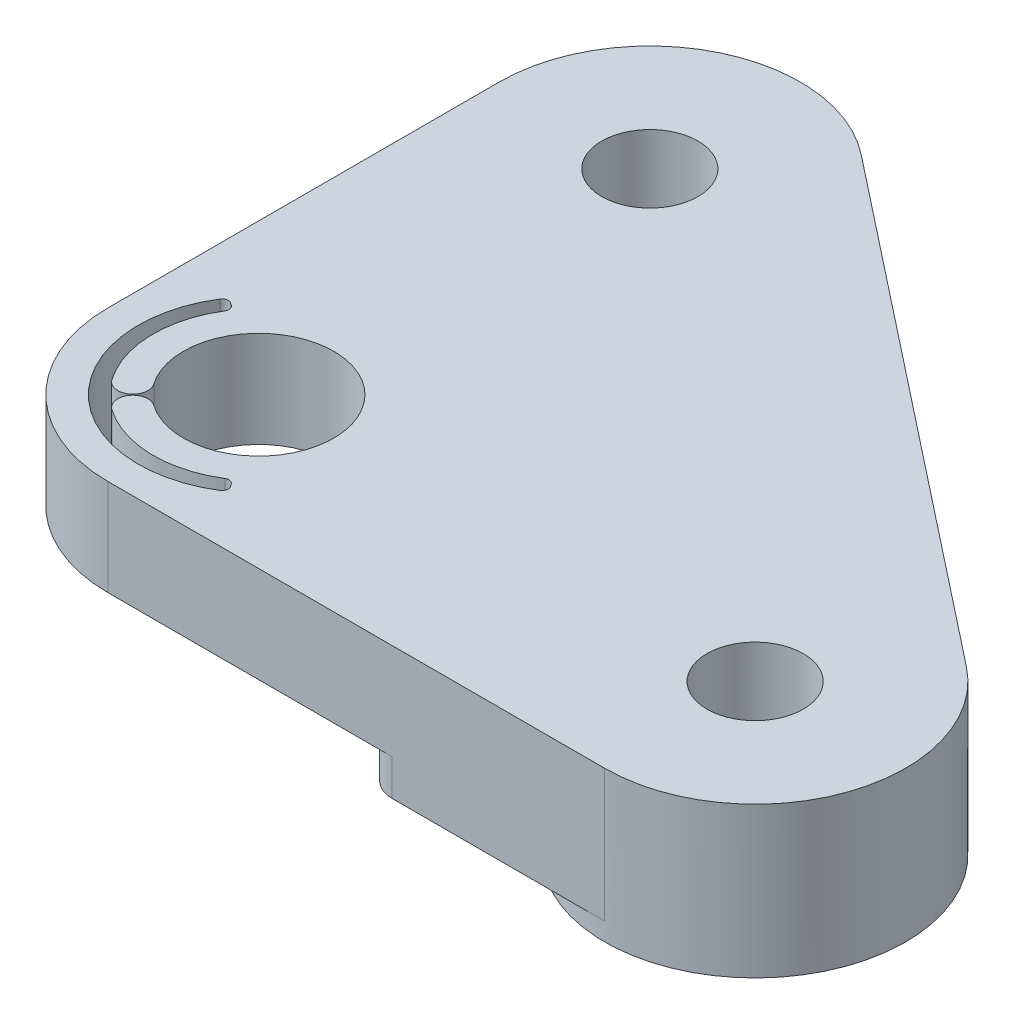
from build123d import *
from build123d.topology import SkipClean

# Parameters (mm, degrees)
SKETCH1_R               = 1.6
SKETCH1_R_2             = 2.5
BOSS_EXTRUDE1_DEPTH     = 1.57
FILLET1_R               = 5
SKETCH2_R               = 2.5
SKETCH2_R_2             = 1.6
BOSS_EXTRUDE2_DEPTH     = 2.83
SKETCH3_R               = 5
SKETCH3_R_2             = 1.6
BOSS_EXTRUDE3_DEPTH     = 0.6
CUT_EXTRUDE1_START      = -10
CUT_EXTRUDE1_DEPTH      = 10
SKETCH5_W               = 1.221153846
SKETCH5_H               = 0.325641026
PART_NUM_LEFT_DEPTH     = 0.4
CUT_EXTRUDE3_DEPTH      = 1
CUT_EXTRUDE3_DEPTH_BACK = 1.2
SKETCH8_R               = 9.25
FILLET3_R               = 1


with BuildPart() as part:
    # Sketch1 → Boss-Extrude1 (new body)
    with BuildSketch(Plane(origin=(0, 0, 0), x_dir=(1, 0, 0), z_dir=(0, 1, 0))):
        Polygon((-5, -5), (30.925365976, -5), (-5, 23.304833799), align=None)
        with Locations((16.5, 0)):
            Circle(SKETCH1_R, mode=Mode.SUBTRACT)
        Circle(SKETCH1_R_2, mode=Mode.SUBTRACT)
        with Locations((0, 13)):
            Circle(SKETCH1_R, mode=Mode.SUBTRACT)
    extrude(amount=BOSS_EXTRUDE1_DEPTH)

    # Fillet1
    fillet1_edges = [part.edges().sort_by_distance(p)[0] for p in [
        (-5, 0.785, -23.304833799),
        (-5, 0.785, 5),
        (30.925365976, 0.785, 5),
    ]]
    fillet(fillet1_edges, radius=FILLET1_R)

    # Sketch2 → Boss-Extrude2 (add)
    with BuildSketch(Plane(origin=(0, 1.57, 0), x_dir=(1, 0, 0), z_dir=(0, 1, 0))):
        with BuildLine():
            Line((19.594361133, 3.927458361), (3.094361133, 16.927458361))
            ThreePointArc((3.094361133, 16.927458361), (-2.182681188, 17.498433375), (-5, 13))
            Line((-5, 13), (-5, 0))
            ThreePointArc((-5, 0), (-3.535533906, -3.535533906), (0, -5))
            Line((0, -5), (16.5, -5))
            ThreePointArc((16.5, -5), (21.224261413, -1.637484075), (19.594361133, 3.927458361))
        make_face()
        Circle(SKETCH2_R, mode=Mode.SUBTRACT)
        with Locations((16.5, 0)):
            Circle(SKETCH2_R_2, mode=Mode.SUBTRACT)
        with Locations((0, 13)):
            Circle(SKETCH2_R_2, mode=Mode.SUBTRACT)
    extrude(amount=BOSS_EXTRUDE2_DEPTH)

    # Sketch3 → Boss-Extrude3 (add)
    # profile 1 of 2: a face of its own
    with SkipClean():  # the faces are left unmerged after this step: merging them gives an invalid solid
        with BuildSketch(Plane.XZ):
            with Locations((16.5, 0)):
                Circle(SKETCH3_R)
            with Locations((16.5, 0)):
                Circle(SKETCH3_R_2, mode=Mode.SUBTRACT)
        # profile 2 of 2: a face of its own
        with BuildSketch(Plane.XZ):
            with Locations((0, -13)):
                Circle(SKETCH3_R)
            with Locations((0, -13)):
                Circle(SKETCH3_R_2, mode=Mode.SUBTRACT)
        extrude(amount=BOSS_EXTRUDE3_DEPTH)
    add(part.part.scale(1), mode=Mode.REPLACE)  # the faces are merged on a copy

    # Sketch4 → Cut-Extrude1 (cut)
    with BuildSketch(Plane(origin=(0, 4.4, 0), x_dir=(1, 0, 0), z_dir=(0, 1, 0)).offset(CUT_EXTRUDE1_START)):
        with BuildLine():
            Line((2.119130133, -3.026431476), (2.176569541, -3.108463452))
            ThreePointArc((2.176569541, -3.108463452), (2.208718169, -3.263081334), (2.118672771, -3.392819725))
            ThreePointArc((2.118672771, -3.392819725), (-2.828427125, -2.828427125), (-3.392819725, 2.118672771))
            ThreePointArc((-3.392819725, 2.118672771), (-3.263081334, 2.208718169), (-3.108463452, 2.176569541))
            Line((-3.108463452, 2.176569541), (-3.026431476, 2.119130133))
            ThreePointArc((-3.026431476, 2.119130133), (-2.945196197, 1.995341896), (-2.971355046, 1.849607847))
            ThreePointArc((-2.971355046, 1.849607847), (-3.498720526, -0.094629188), (-2.867032155, -2.007517527))
            ThreePointArc((-2.867032155, -2.007517527), (-2.170667915, -2.130305331), (-2.047880111, -1.433941091))
            ThreePointArc((-2.047880111, -1.433941091), (-1.767766953, -1.767766953), (-1.433941091, -2.047880111))
            ThreePointArc((-1.433941091, -2.047880111), (-2.130305331, -2.170667915), (-2.007517527, -2.867032155))
            ThreePointArc((-2.007517527, -2.867032155), (-0.094629188, -3.498720526), (1.849607847, -2.971355046))
            ThreePointArc((1.849607847, -2.971355046), (1.995341896, -2.945196197), (2.119130133, -3.026431476))
        make_face()
    extrude(amount=CUT_EXTRUDE1_DEPTH, mode=Mode.SUBTRACT)

    # Sketch5 → Part Num Left (cut)
    # profile 1 of 6: a face of its own
    with BuildSketch(Plane(origin=(9.413907875, 0, -11.948421534), x_dir=(-0.7854916722275357, 0, -0.6188722266035127), z_dir=(0.6188722266035127, 0, -0.7854916722275357))):
        Polygon((-9.377508618, 3.775), (-9.09257272, 3.775), (-9.09257272, 0.925641026), (-7.871418874, 0.925641026), (-7.871418874, 0.6), (-9.377508618, 0.6), align=None)
    # profile 2 of 6: a face of its own
    with BuildSketch(Plane(origin=(9.413907875, 0, -11.948421534), x_dir=(-0.7854916722275357, 0, -0.6188722266035127), z_dir=(0.6188722266035127, 0, -0.7854916722275357))):
        with BuildLine():
            Line((-4.411482977, 3.192407853), (-4.660801887, 3.001602564))
            add(Edge.make_bspline(
                [(-4.660801887, 3.001602564), (-4.678587229, 3.022798837), (-4.713918127, 3.06490561), (-4.770758975, 3.124032768), (-4.829996894, 3.179427684), (-4.891609239, 3.231354246), (-4.956705012, 3.277996598), (-5.023707308, 3.321785384), (-5.093736963, 3.361035404), (-5.190576037, 3.408626827), (-5.317256585, 3.45828941), (-5.476727618, 3.499930199), (-5.6431984, 3.52643798), (-5.756770508, 3.529308943), (-5.814537865, 3.530769231)],
                knots=[0, 0, 0, 0, 0.757959112, 1.505699292, 2.245454638, 2.979532153, 3.711538275, 4.438200793, 5.171680507, 5.909471876, 7.393775596, 8.890124382, 10.418191784, 12, 12, 12, 12], degree=3))
            add(Edge.make_bspline(
                [(-5.814537865, 3.530769231), (-5.846363429, 3.530402779), (-5.909719187, 3.529673277), (-6.003743159, 3.520049285), (-6.096011427, 3.506522687), (-6.186463971, 3.486451858), (-6.274985655, 3.461076696), (-6.362155191, 3.430755071), (-6.446710521, 3.393240323), (-6.529821351, 3.351776402), (-6.609449636, 3.304942934), (-6.684792429, 3.253858679), (-6.755574943, 3.199095284), (-6.821853169, 3.140447495), (-6.883694865, 3.078179431), (-6.940651926, 3.011627492), (-6.992527262, 2.941004449), (-7.040349135, 2.867241573), (-7.083177829, 2.790553719), (-7.119037077, 2.710657048), (-7.150791723, 2.628919754), (-7.175918893, 2.544418344), (-7.195807562, 2.457747406), (-7.209530514, 2.368674334), (-7.219045056, 2.277385211), (-7.21977093, 2.21550962), (-7.220136823, 2.184319912)],
                knots=[0, 0, 0, 0, 1.054917814, 2.100044995, 3.131103042, 4.146048494, 5.169673617, 6.183595914, 7.203665975, 8.234915748, 9.262203917, 10.264457458, 11.251630812, 12.227803204, 13.197192746, 14.159520551, 15.12972552, 16.100847026, 17.073214652, 18.039054194, 19.002613845, 19.979014051, 20.95965708, 21.949030935, 22.966165397, 24, 24, 24, 24], degree=3))
            add(Edge.make_bspline(
                [(-7.220136823, 2.184319912), (-7.218992173, 2.137392215), (-7.216744804, 2.045255905), (-7.196743815, 1.910299709), (-7.166349911, 1.781013097), (-7.120797209, 1.658204241), (-7.064627785, 1.540358801), (-6.993652373, 1.429470699), (-6.911450228, 1.323864244), (-6.816858434, 1.226035284), (-6.713076015, 1.136669262), (-6.601726123, 1.057974091), (-6.483086091, 0.992374162), (-6.358465862, 0.937785982), (-6.226906459, 0.895824522), (-6.08864446, 0.86628421), (-5.943980578, 0.847014518), (-5.845129765, 0.845169672), (-5.794821318, 0.844230769)],
                knots=[0, 0, 0, 0, 1.029171465, 2.020641659, 2.987623507, 3.938342917, 4.889210282, 5.84687017, 6.821220943, 7.821438502, 8.827599549, 9.822697543, 10.807740252, 11.797342354, 12.80366471, 13.83203677, 14.896651826, 16, 16, 16, 16], degree=3))
            add(Edge.make_bspline(
                [(-5.794821318, 0.844230769), (-5.73939245, 0.845762734), (-5.630295179, 0.848778006), (-5.470304183, 0.874322468), (-5.317146024, 0.915740722), (-5.170812464, 0.973705266), (-5.031716035, 1.049057348), (-4.899639064, 1.140404709), (-4.774470068, 1.248616268), (-4.699203262, 1.331241677), (-4.660801887, 1.373397436)],
                knots=[0, 0, 0, 0, 1.028121516, 2.023589091, 2.998037872, 3.967518031, 4.937445131, 5.927275754, 6.942489185, 8, 8, 8, 8], degree=3))
            Line((-4.660801887, 1.373397436), (-4.411482977, 1.1845002))
            add(Edge.make_bspline(
                [(-4.411482977, 1.1845002), (-4.431547262, 1.158611748), (-4.471579726, 1.106958846), (-4.536402356, 1.034140938), (-4.604689619, 0.965647992), (-4.676948727, 0.902032221), (-4.752348438, 0.84202067), (-4.832242607, 0.787318294), (-4.915580944, 0.737161564), (-5.002081078, 0.691235711), (-5.091651105, 0.650489351), (-5.1841837, 0.61560629), (-5.279280008, 0.585557283), (-5.376944376, 0.560835883), (-5.477379384, 0.541539972), (-5.5802226, 0.528640695), (-5.685695987, 0.519803387), (-5.756853561, 0.518997921), (-5.792913265, 0.518589744)],
                knots=[0, 0, 0, 0, 0.986787822, 1.968848986, 2.935600012, 3.899624008, 4.868462664, 5.837806735, 6.815139263, 7.798259679, 8.787526145, 9.778297419, 10.776456485, 11.791383307, 12.812564526, 13.85620153, 14.913611965, 16, 16, 16, 16], degree=3))
            add(Edge.make_bspline(
                [(-5.792913265, 0.518589744), (-5.827061449, 0.518827408), (-5.894585254, 0.519297361), (-5.994279121, 0.526910255), (-6.091333955, 0.537296803), (-6.185472366, 0.552936064), (-6.277208072, 0.571391287), (-6.365709459, 0.596130213), (-6.4518474, 0.623842671), (-6.535275823, 0.656413623), (-6.616065694, 0.693167589), (-6.693956437, 0.734707074), (-6.768912229, 0.780682766), (-6.841670004, 0.83008124), (-6.911154955, 0.884489221), (-6.977969224, 0.943151096), (-7.04248747, 1.005869149), (-7.082404192, 1.051094623), (-7.102473562, 1.073833133)],
                knots=[0, 0, 0, 0, 1.114604814, 2.203992996, 3.262667896, 4.300477797, 5.318619304, 6.316056647, 7.298880507, 8.271930387, 9.238335007, 10.195173496, 11.151986948, 12.108099108, 13.064862484, 14.031167946, 15.010108607, 16, 16, 16, 16], degree=3))
            add(Edge.make_bspline(
                [(-7.102473562, 1.073833133), (-7.134618753, 1.113331212), (-7.198521049, 1.191850513), (-7.28027792, 1.319109939), (-7.350261773, 1.451977528), (-7.406845644, 1.591151321), (-7.451080409, 1.736319022), (-7.481724779, 1.88755381), (-7.50163802, 2.044714444), (-7.503915211, 2.151609245), (-7.50507272, 2.205944511)],
                knots=[0, 0, 0, 0, 0.994628077, 1.977248131, 2.950237994, 3.925870899, 4.908910175, 5.911660606, 6.938484602, 8, 8, 8, 8], degree=3))
            add(Edge.make_bspline(
                [(-7.50507272, 2.205944511), (-7.503661938, 2.263054101), (-7.500886311, 2.375413654), (-7.477304411, 2.540308598), (-7.439368788, 2.698288795), (-7.385487325, 2.849059335), (-7.317174614, 2.993413232), (-7.232786185, 3.130247753), (-7.133302421, 3.260437993), (-7.019503556, 3.382008518), (-6.89471033, 3.493169216), (-6.76107112, 3.590964844), (-6.618847497, 3.672351447), (-6.469606303, 3.74038368), (-6.312230006, 3.792675443), (-6.147054378, 3.829281549), (-5.974389791, 3.852066361), (-5.856586019, 3.854946728), (-5.796729371, 3.856410256)],
                knots=[0, 0, 0, 0, 1.032925535, 2.032216505, 3.007276963, 3.968222605, 4.92396291, 5.891752235, 6.871517503, 7.883894988, 8.900124299, 9.891468569, 10.874487609, 11.85992873, 12.854644235, 13.869047385, 14.917252991, 16, 16, 16, 16], degree=3))
            add(Edge.make_bspline(
                [(-5.796729371, 3.856410256), (-5.7602491, 3.855972888), (-5.688040078, 3.855107162), (-5.5812216, 3.846665162), (-5.477224632, 3.832592104), (-5.375977527, 3.813436813), (-5.276987725, 3.789663028), (-5.181011792, 3.7586929), (-5.087486555, 3.72328119), (-4.99700186, 3.682497439), (-4.909991846, 3.636716895), (-4.826483614, 3.586447007), (-4.747140493, 3.531750098), (-4.67140418, 3.47309136), (-4.600541617, 3.40922981), (-4.532540847, 3.341921991), (-4.469711155, 3.269229165), (-4.4309279, 3.218061832), (-4.411482977, 3.192407853)],
                knots=[0, 0, 0, 0, 1.096760587, 2.17092713, 3.219439832, 4.250915756, 5.268269357, 6.278326846, 7.281116186, 8.274029601, 9.260640565, 10.235837813, 11.203064059, 12.156899882, 13.114053108, 14.069676657, 15.032185724, 16, 16, 16, 16], degree=3))
        make_face()
    # profile 3 of 6: a face of its own
    with BuildSketch(Plane(origin=(9.413907875, 0, -11.948421534), x_dir=(-0.7854916722275357, 0, -0.6188722266035127), z_dir=(0.6188722266035127, 0, -0.7854916722275357))):
        with BuildLine():
            Line((-3.760200926, 3.775), (-3.124819315, 3.775))
            add(Edge.make_bspline(
                [(-3.124819315, 3.775), (-3.082418434, 3.774858861), (-3.001004046, 3.774587859), (-2.884369722, 3.773076774), (-2.778390856, 3.768745752), (-2.683122858, 3.76501868), (-2.598567479, 3.758222418), (-2.524465436, 3.751726689), (-2.461158025, 3.743223439), (-2.422835003, 3.735326377), (-2.405483377, 3.731750801)],
                knots=[0, 0, 0, 0, 1.410062039, 2.707475311, 3.878576406, 4.937260626, 5.877586885, 6.699081471, 7.410979367, 8, 8, 8, 8], degree=3))
            add(Edge.make_bspline(
                [(-2.405483377, 3.731750801), (-2.382254511, 3.726011521), (-2.336292314, 3.714655396), (-2.270116182, 3.690652758), (-2.20705676, 3.662876384), (-2.147375991, 3.630252152), (-2.091372809, 3.592537888), (-2.03846977, 3.550384662), (-1.988426814, 3.504023126), (-1.943267763, 3.452284377), (-1.900687338, 3.398004114), (-1.864774798, 3.339308563), (-1.833817206, 3.277929892), (-1.809169665, 3.213243877), (-1.789323218, 3.145877841), (-1.775329415, 3.075221576), (-1.766937266, 3.001596977), (-1.766082869, 2.951379445), (-1.765649643, 2.925916466)],
                knots=[0, 0, 0, 0, 1.027469482, 2.033020251, 3.019912614, 3.986113645, 4.951240523, 5.91722682, 6.890402269, 7.87763091, 8.8651537, 9.85103654, 10.82876324, 11.815024772, 12.821070561, 13.842952187, 14.906261191, 16, 16, 16, 16], degree=3))
            add(Edge.make_bspline(
                [(-1.765649643, 2.925916466), (-1.766982235, 2.883611764), (-1.769582465, 2.801064333), (-1.793825952, 2.681266248), (-1.833537509, 2.569515941), (-1.88825935, 2.46595412), (-1.957945589, 2.372599463), (-2.041697363, 2.290602407), (-2.139561397, 2.221986201), (-2.230665133, 2.174404013), (-2.311141586, 2.143930446), (-2.377393234, 2.122488892), (-2.449662563, 2.105922681), (-2.527257146, 2.091081704), (-2.61049989, 2.079876953), (-2.699191283, 2.071670399), (-2.793394578, 2.066541369), (-2.858109305, 2.065777551), (-2.891400845, 2.065384615)],
                knots=[0, 0, 0, 0, 1.260483769, 2.459530307, 3.627416485, 4.787058657, 5.939039949, 7.08810263, 8.267026773, 9.491475466, 10.141966685, 10.831826277, 11.566392101, 12.351337768, 13.187381173, 14.07005841, 15.007169909, 16, 16, 16, 16], degree=3))
            Line((-2.891400845, 2.065384615), (-1.724944515, 0.6))
            Line((-1.724944515, 0.6), (-2.077298281, 0.6))
            Line((-2.077298281, 0.6), (-3.243754611, 2.065384615))
            Line((-3.243754611, 2.065384615), (-3.475265028, 2.065384615))
            Line((-3.475265028, 2.065384615), (-3.475265028, 0.6))
            Line((-3.475265028, 0.6), (-3.760200926, 0.6))
            Line((-3.760200926, 0.6), (-3.760200926, 3.775))
        make_face()
        with BuildLine():
            Line((-3.475265028, 3.449358974), (-3.475265028, 2.391025641))
            Line((-3.475265028, 2.391025641), (-2.893944916, 2.386573518))
            add(Edge.make_bspline(
                [(-2.893944916, 2.386573518), (-2.866803166, 2.38656151), (-2.814194725, 2.386538236), (-2.738084836, 2.390161162), (-2.667218735, 2.3942826), (-2.601867481, 2.40058665), (-2.542001881, 2.408711086), (-2.487651856, 2.418873793), (-2.438728688, 2.430713879), (-2.381670728, 2.449039639), (-2.31795616, 2.47807367), (-2.248712621, 2.520315229), (-2.189746215, 2.573445788), (-2.139927868, 2.63420028), (-2.09989617, 2.700998877), (-2.071673092, 2.773040869), (-2.053763876, 2.848507533), (-2.051651553, 2.900376245), (-2.050585541, 2.926552484)],
                knots=[0, 0, 0, 0, 1.146690395, 2.22261258, 3.21895312, 4.145990853, 4.996080663, 5.770904154, 6.481378293, 7.121626537, 8.300444488, 9.431385265, 10.535395872, 11.636531494, 12.74115979, 13.810798291, 14.895190096, 16, 16, 16, 16], degree=3))
            add(Edge.make_bspline(
                [(-2.050585541, 2.926552484), (-2.051676036, 2.952085447), (-2.053837001, 3.002682464), (-2.071479812, 3.07675604), (-2.10131518, 3.146666773), (-2.141521781, 3.21213027), (-2.190506729, 3.27155333), (-2.24794503, 3.322396105), (-2.312266172, 3.364350976), (-2.372383616, 3.391161022), (-2.426117509, 3.407598317), (-2.472771557, 3.419165444), (-2.525486969, 3.428458641), (-2.584519707, 3.435904525), (-2.649617758, 3.442304367), (-2.721110277, 3.446614909), (-2.798522927, 3.449167486), (-2.852177644, 3.449293659), (-2.879952528, 3.449358974)],
                knots=[0, 0, 0, 0, 1.101028733, 2.181837193, 3.264309656, 4.369019818, 5.486613113, 6.575447106, 7.666700264, 8.788928104, 9.402425223, 10.0903467, 10.862060571, 11.710948788, 12.657782767, 13.684531032, 14.801375019, 16, 16, 16, 16], degree=3))
            Line((-2.879952528, 3.449358974), (-3.475265028, 3.449358974))
        make_face(mode=Mode.SUBTRACT)
    # profile 4 of 6: a face of its own
    with BuildSketch(Plane(origin=(9.413907875, 0, -11.948421534), x_dir=(-0.7854916722275357, 0, -0.6188722266035127), z_dir=(0.6188722266035127, 0, -0.7854916722275357))):
        with Locations((-0.748021438, 1.821153846)):
            Rectangle(SKETCH5_W, SKETCH5_H)
    # profile 5 of 6: a face of its own
    with BuildSketch(Plane(origin=(9.413907875, 0, -11.948421534), x_dir=(-0.7854916722275357, 0, -0.6188722266035127), z_dir=(0.6188722266035127, 0, -0.7854916722275357))):
        with BuildLine():
            add(Edge.make_bspline(
                [(0.106786254, 2.186227965), (0.107083813, 2.237116309), (0.107661827, 2.335967652), (0.114092037, 2.480008006), (0.124773955, 2.615136268), (0.139412857, 2.741358907), (0.157227311, 2.858708507), (0.181008502, 2.966871466), (0.208052973, 3.066348394), (0.239396977, 3.157463681), (0.274764472, 3.241444883), (0.313258408, 3.319844887), (0.356406472, 3.392545069), (0.401742671, 3.460705779), (0.451102194, 3.523211273), (0.503080382, 3.58094426), (0.559705941, 3.632570441), (0.619053956, 3.679602444), (0.681661749, 3.720831607), (0.745744739, 3.75714702), (0.811744013, 3.788171185), (0.879839765, 3.812564652), (0.949419942, 3.832713063), (1.020727781, 3.846491609), (1.093881019, 3.85516109), (1.143258106, 3.855989917), (1.168299675, 3.856410256)],
                knots=[0, 0, 0, 0, 1.646270934, 3.197905019, 4.663502075, 6.030701355, 7.308322542, 8.50163776, 9.611534131, 10.641858119, 11.616356847, 12.558055219, 13.465016945, 14.349605745, 15.204443733, 16.039544428, 16.859896111, 17.680448484, 18.487036065, 19.28249412, 20.06191084, 20.843045899, 21.620316918, 22.403196591, 23.190181807, 24, 24, 24, 24], degree=3))
            add(Edge.make_bspline(
                [(1.168299675, 3.856410256), (1.193550431, 3.855967738), (1.243766239, 3.855087709), (1.318007151, 3.846629561), (1.390532934, 3.832595043), (1.461034388, 3.812709587), (1.530090626, 3.788039223), (1.59716151, 3.757117338), (1.662663648, 3.721122937), (1.725556123, 3.67882842), (1.786529381, 3.631673069), (1.844085748, 3.578366934), (1.898230461, 3.51944826), (1.94964306, 3.455547427), (1.996864923, 3.385438814), (2.041835108, 3.3103418), (2.082086883, 3.228943087), (2.120853339, 3.142600805), (2.154315105, 3.048925915), (2.184492342, 2.948446454), (2.208875406, 2.839975584), (2.229185675, 2.724082419), (2.244919973, 2.600341345), (2.256379584, 2.469017616), (2.262433026, 2.330024833), (2.263573033, 2.234994498), (2.264158049, 2.186227965)],
                knots=[0, 0, 0, 0, 0.810914788, 1.612654377, 2.396697861, 3.181598691, 3.963628158, 4.749916497, 5.551656086, 6.361998678, 7.18212741, 8.025565596, 8.878627764, 9.750805457, 10.657531673, 11.591944965, 12.560506719, 13.57287815, 14.630710178, 15.753379473, 16.941251878, 18.199788006, 19.531962791, 20.947069417, 22.433333509, 24, 24, 24, 24], degree=3))
            add(Edge.make_bspline(
                [(2.264158049, 2.186227965), (2.263566969, 2.137674134), (2.262415273, 2.043068975), (2.256447446, 1.90470159), (2.244692116, 1.774074794), (2.229987341, 1.650875303), (2.20962111, 1.535615891), (2.184579281, 1.427897713), (2.15677506, 1.327255591), (2.122453496, 1.234514012), (2.084888066, 1.148379235), (2.044016567, 1.067945464), (2.000228939, 0.992501756), (1.952523435, 0.922651986), (1.901674981, 0.857901347), (1.846595273, 0.799392789), (1.788836956, 0.745716537), (1.727684265, 0.697953989), (1.663810929, 0.656148487), (1.598533766, 0.618761637), (1.530694554, 0.588614835), (1.461830661, 0.562729477), (1.390957072, 0.542953353), (1.318162132, 0.529279212), (1.243816118, 0.519689035), (1.193558984, 0.518957443), (1.168299675, 0.518589744)],
                knots=[0, 0, 0, 0, 1.561518951, 3.042555995, 4.452378317, 5.7783523, 7.031515105, 8.214008947, 9.334062868, 10.386615937, 11.391082383, 12.354592575, 13.286541444, 14.194233754, 15.072674879, 15.931287219, 16.775624067, 17.606195743, 18.42308326, 19.229000347, 20.022332153, 20.807536673, 21.593273796, 22.3848459, 23.188221202, 24, 24, 24, 24], degree=3))
            add(Edge.make_bspline(
                [(1.168299675, 0.518589744), (1.143258801, 0.519012795), (1.093883083, 0.519846969), (1.020719811, 0.528477282), (0.949706452, 0.542352489), (0.880492582, 0.561780408), (0.812723101, 0.58556101), (0.747321469, 0.61654328), (0.683560499, 0.652224899), (0.621610302, 0.692860746), (0.562634984, 0.739416844), (0.506302678, 0.790910163), (0.454028554, 0.848625686), (0.405374767, 0.911652088), (0.359133987, 0.979409529), (0.316598627, 1.052823125), (0.277255066, 1.131601779), (0.241292757, 1.216254455), (0.209407898, 1.308016425), (0.181243191, 1.407937466), (0.159005348, 1.516899507), (0.13997081, 1.634027404), (0.124617977, 1.75982447), (0.114136554, 1.894358997), (0.107658361, 2.037547151), (0.107082261, 2.135763303), (0.106786254, 2.186227965)],
                knots=[0, 0, 0, 0, 0.810891512, 1.598919785, 2.382837074, 3.152667961, 3.926044502, 4.706494248, 5.493654104, 6.291793342, 7.103789334, 7.925228297, 8.761435821, 9.622817696, 10.50288917, 11.416980706, 12.369136599, 13.353924996, 14.394355917, 15.514179734, 16.714354668, 17.994756427, 19.357759367, 20.818452758, 22.365282078, 24, 24, 24, 24], degree=3))
        make_face()
        with BuildLine():
            add(Edge.make_bspline(
                [(0.391722151, 2.1875), (0.391830507, 2.145092252), (0.392040804, 2.06278714), (0.397534643, 1.943186467), (0.405018782, 1.831634812), (0.414671959, 1.727990532), (0.429007491, 1.63260445), (0.445070077, 1.544820523), (0.464617272, 1.465103315), (0.487744896, 1.392905801), (0.514087505, 1.327002717), (0.542849253, 1.265678758), (0.573747194, 1.208209501), (0.608326709, 1.155111156), (0.645986802, 1.106210565), (0.68587683, 1.06064221), (0.729485532, 1.020004948), (0.789813927, 0.971267015), (0.869457871, 0.92090323), (0.969806427, 0.87704642), (1.072919951, 0.849485191), (1.142907156, 0.845980213), (1.17783994, 0.844230769)],
                knots=[0, 0, 0, 0, 1.459021318, 2.831673884, 4.118529203, 5.306027144, 6.411944654, 7.436330062, 8.375795394, 9.233974572, 10.042671642, 10.816086306, 11.563610507, 12.285937304, 12.993564865, 13.685989202, 14.367179055, 15.041617293, 16.353048772, 17.594441528, 18.799311195, 20, 20, 20, 20], degree=3))
            add(Edge.make_bspline(
                [(1.17783994, 0.844230769), (1.212998685, 0.845680185), (1.283243585, 0.848576023), (1.385872099, 0.876514878), (1.485503844, 0.918669388), (1.56358339, 0.968514626), (1.622985412, 1.015983896), (1.665545824, 1.056455755), (1.704609254, 1.101772864), (1.74165885, 1.150667225), (1.775639583, 1.204072978), (1.806539715, 1.261733315), (1.834736752, 1.323808354), (1.850801387, 1.367142332), (1.85901482, 1.389297877)],
                knots=[0, 0, 0, 0, 1.353760809, 2.704726607, 4.075137775, 5.516104923, 6.260822281, 7.007110065, 7.778089737, 8.566572457, 9.372053459, 10.217411131, 11.088608312, 12, 12, 12, 12], degree=3))
            add(Edge.make_bspline(
                [(1.85901482, 1.389297877), (1.86858678, 1.417627712), (1.888021966, 1.475149426), (1.91306979, 1.564379311), (1.932795973, 1.657998961), (1.950542741, 1.755448888), (1.96265587, 1.85744776), (1.972405672, 1.96367998), (1.978148509, 2.074225644), (1.978860391, 2.149332529), (1.979222151, 2.1875)],
                knots=[0, 0, 0, 0, 0.884706709, 1.796334032, 2.740027952, 3.714592787, 4.726048262, 5.777819803, 6.87074269, 8, 8, 8, 8], degree=3))
            add(Edge.make_bspline(
                [(1.979222151, 2.1875), (1.978723051, 2.225661298), (1.977746704, 2.300312955), (1.97401473, 2.409640161), (1.96437763, 2.513478773), (1.953674144, 2.61227613), (1.937892379, 2.705485333), (1.920876368, 2.793886682), (1.898015269, 2.876384997), (1.873595187, 2.954271903), (1.845645757, 3.026662497), (1.814879341, 3.093894289), (1.782021031, 3.156291861), (1.746331999, 3.213684015), (1.708235915, 3.266327822), (1.666727281, 3.313167775), (1.6234526, 3.355655596), (1.562839867, 3.404153784), (1.48348819, 3.453603679), (1.384749638, 3.49911119), (1.281996982, 3.525244427), (1.21253392, 3.528928957), (1.17783994, 3.530769231)],
                knots=[0, 0, 0, 0, 1.31362396, 2.569729283, 3.763502607, 4.902122613, 5.988968491, 7.01645872, 7.998833611, 8.933434873, 9.825090667, 10.667526885, 11.477055099, 12.250526234, 12.991942729, 13.710640831, 14.402115721, 15.076753259, 16.378508321, 17.609869233, 18.806226677, 20, 20, 20, 20], degree=3))
            add(Edge.make_bspline(
                [(1.17783994, 3.530769231), (1.142723903, 3.528926418), (1.072427856, 3.525237437), (0.968607211, 3.499208557), (0.869089692, 3.453839652), (0.789947851, 3.40399), (0.729292844, 3.356511674), (0.686582115, 3.315339677), (0.64653523, 3.270303432), (0.609643817, 3.220953123), (0.575091396, 3.167916683), (0.54335862, 3.110776875), (0.514767899, 3.049244137), (0.48838407, 2.983370657), (0.465185898, 2.911179371), (0.44605066, 2.831560356), (0.428373119, 2.744055639), (0.415858839, 2.648152943), (0.404733861, 2.544482704), (0.397584352, 2.432652565), (0.392022426, 2.312851306), (0.391824248, 2.230120641), (0.391722151, 2.1875)],
                knots=[0, 0, 0, 0, 1.207732386, 2.417664972, 3.655092373, 4.956220595, 5.625982001, 6.301752483, 6.994047911, 7.697131622, 8.419323945, 9.170223765, 9.943494443, 10.752040957, 11.610060368, 12.549350801, 13.567764191, 14.679664412, 15.874934091, 17.154273443, 18.533957287, 20, 20, 20, 20], degree=3))
        make_face(mode=Mode.SUBTRACT)
    # profile 6 of 6: a face of its own
    with BuildSketch(Plane(origin=(9.413907875, 0, -11.948421534), x_dir=(-0.7854916722275357, 0, -0.6188722266035127), z_dir=(0.6188722266035127, 0, -0.7854916722275357))):
        Polygon((3.22390865, 3.775), (3.810952921, 3.775), (3.810952921, 0.6), (3.526017023, 0.6), (3.526017023, 3.449358974), (3.037555485, 3.449358974), align=None)
    extrude(amount=-PART_NUM_LEFT_DEPTH, mode=Mode.SUBTRACT)

    # Sketch8 → Cut-Extrude3 (cut, two sides: drawn at the far end of the back side and taken through both)
    with BuildSketch(Plane.XZ.offset(-CUT_EXTRUDE3_DEPTH_BACK)):
        Circle(SKETCH8_R)
    extrude(amount=CUT_EXTRUDE3_DEPTH + CUT_EXTRUDE3_DEPTH_BACK, mode=Mode.SUBTRACT)

    # Fillet3
    fillet3_edges = [part.edges().sort_by_distance(p)[0] for p in [
        (-5, 0.6, -7.782191208),
        (7.782191208, 0.6, 5),
    ]]
    fillet(fillet3_edges, radius=FILLET3_R)


solid = part.part
